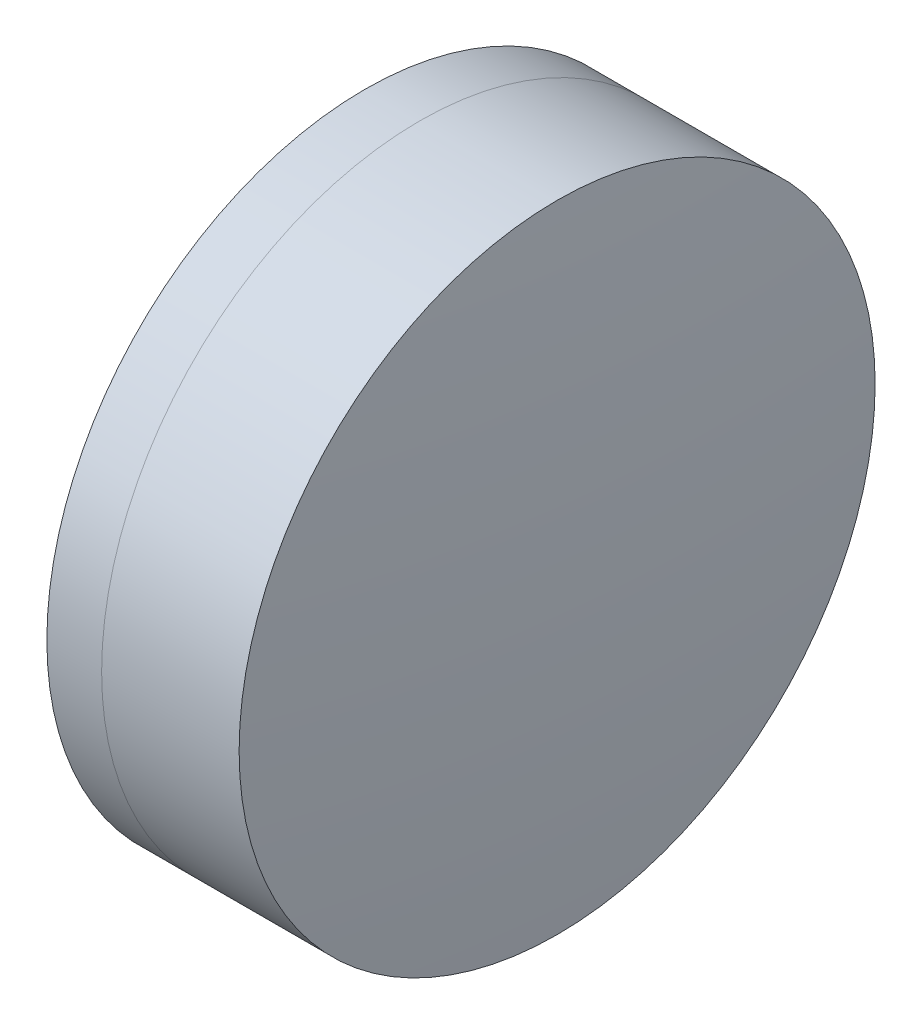
from build123d import *


with BuildPart() as part:
    # 草图1 one side → 旋转1 (revolve)
    with BuildSketch(Plane(origin=(0, 0, 0), x_dir=(1, 0, 0), z_dir=(0, 1, 0)), mode=Mode.PRIVATE) as revolve_1_sk:
        with BuildLine():
            ThreePointArc((22.980765665, 12.7), (20.327206006, 6.594834211), (19.420238586, 0))
            Line((19.420238586, 0), (29.420238586, 0))
            ThreePointArc((29.420238586, 0), (28.328849842, 6.696539989), (25.167640404, 12.7))
            Line((25.167640404, 12.7), (22.980765665, 12.7))
        make_face()
    revolve(revolve_1_sk.sketch.rotate(Axis((-0.816062176, 0, 0), (1, 0, 0)), 180), axis=Axis((-0.816062176, 0, 0), (1, 0, 0)))  # turned: the seam where the file's is


with BuildPart() as body_2:
    # 草图2 one side → 旋转2 (revolve)
    with BuildSketch(Plane(origin=(0, 0, 0), x_dir=(1, 0, 0), z_dir=(0, 1, 0)), mode=Mode.PRIVATE) as revolve_2_sk:
        with BuildLine():
            Line((30.658797451, 12.7), (25.167640404, 12.7))
            ThreePointArc((25.167640404, 12.7), (28.328849842, 6.696539989), (29.420238586, 0))
            Line((29.420238586, 0), (31.220238586, 0))
            ThreePointArc((31.220238586, 0), (31.079809791, 6.356202014), (30.658797451, 12.7))
        make_face()
    revolve(revolve_2_sk.sketch.rotate(Axis((-0.551919993, 0, 0), (1, 0, 0)), 180), axis=Axis((-0.551919993, 0, 0), (1, 0, 0)))  # turned: the seam where the file's is


solid = Compound([part.part, body_2.part])
